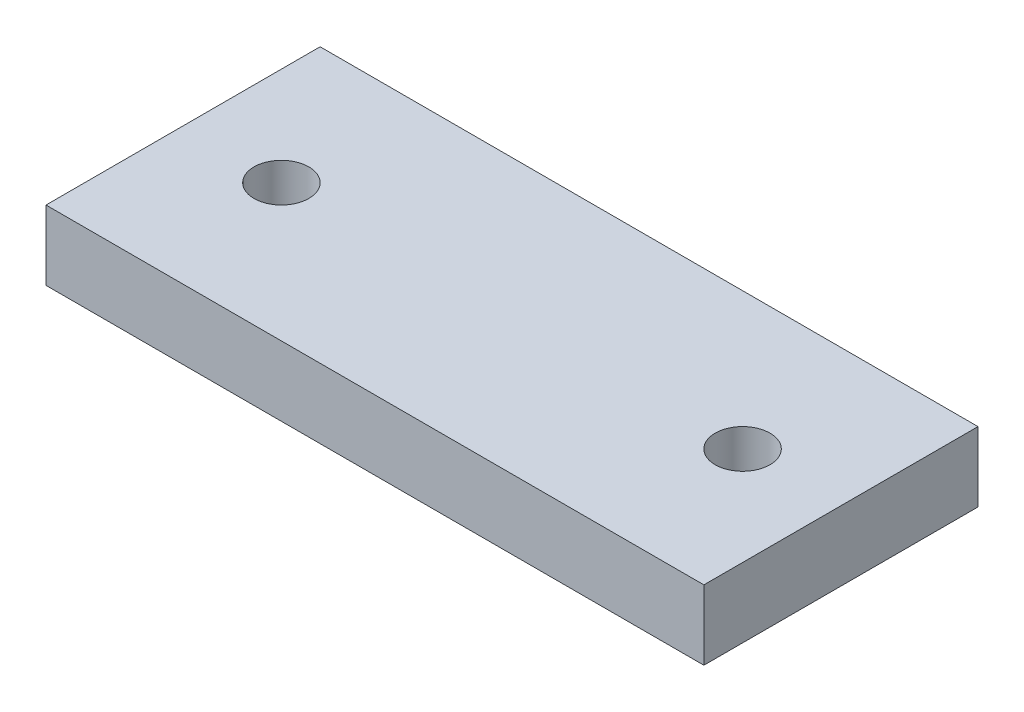
from build123d import *

# Parameters (mm, degrees)
SKETCH1_W           = 60
SKETCH1_H           = 25
SKETCH1_R           = 2.5
BOSS_EXTRUDE1_DEPTH = 6.35


with BuildPart() as part:
    # Sketch1 → Boss-Extrude1 (new body)
    with BuildSketch(Plane(origin=(0, 0, 0), x_dir=(1, 0, 0), z_dir=(0, 1, 0))):
        with Locations((30, 12.5)):
            Rectangle(SKETCH1_W, SKETCH1_H)
        with Locations((8.97, 12.5)):
            Circle(SKETCH1_R, mode=Mode.SUBTRACT)
        with Locations((51.03, 12.5)):
            Circle(SKETCH1_R, mode=Mode.SUBTRACT)
    extrude(amount=BOSS_EXTRUDE1_DEPTH)


solid = part.part
